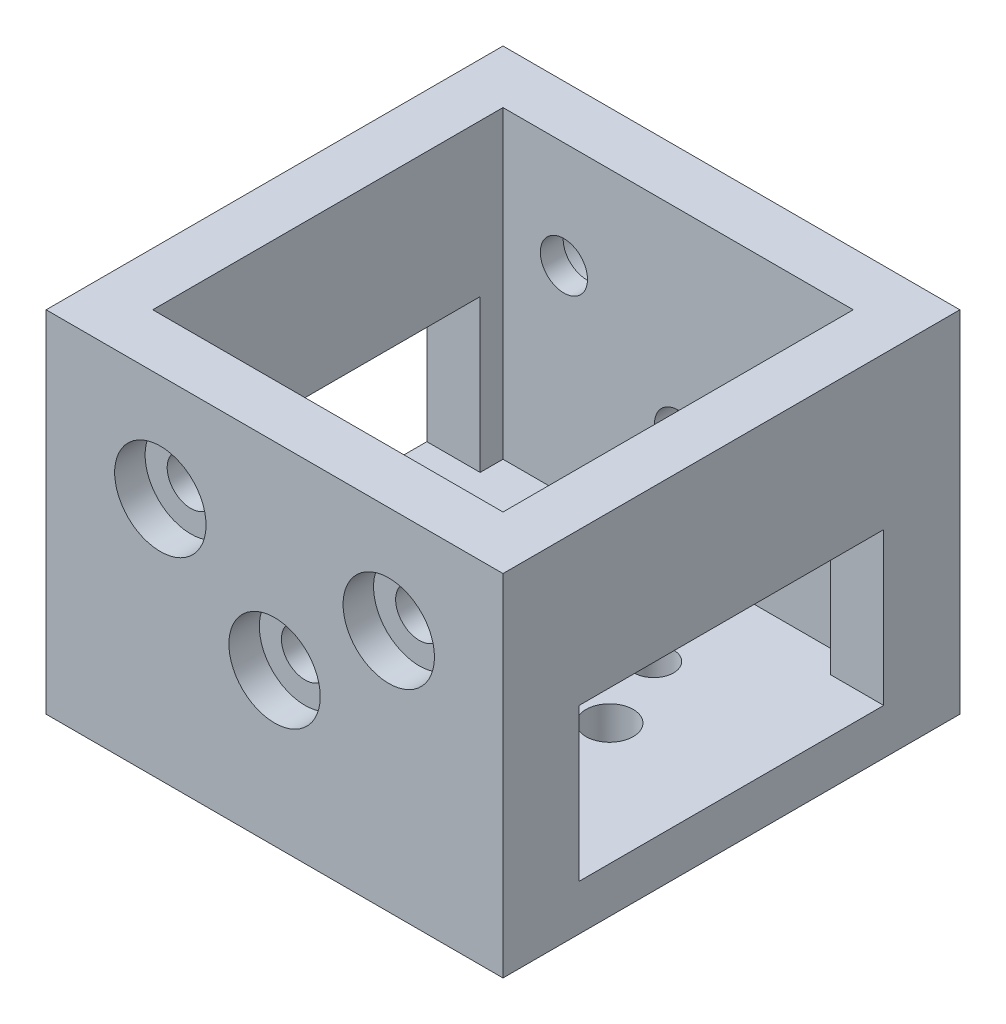
from build123d import *

# Parameters (mm, degrees)
SKETCH_1_W          = 23
SKETCH_1_H          = 30
EXTRUDE_2_DEPTH     = 3
SKETCH_1_4_W        = 23
SKETCH_1_4_H        = 3.5
EXTRUDE_3_DEPTH     = 18
EXTRUDE_3_2_DEPTH   = 18
SKETCH_1_5_W        = 30
SKETCH_1_5_H        = 30
SKETCH_1_5_W_2      = 23
SKETCH_1_5_H_2      = 23
EXTRUDE_4_DEPTH     = 23
SKETCH_3_R          = 1.55
CUT_EXTRUDE_2_DEPTH = 45.171936792
CUT_EXTRUDE_5_DEPTH = 41.669398815
SKETCH_9_R          = 1.3
SKETCH_9_R_2        = 3
SKETCH_9_R_3        = 1.55
CUT_EXTRUDE_6_DEPTH = 32.288975694
SKETCH_10_R         = 3
CUT_EXTRUDE_7_DEPTH = 2
CUT_EXTRUDE_START   = -2
SKETCH_11_R         = 3
CUT_EXTRUDE_8_DEPTH = 2


with BuildPart() as part:
    # 草图1 → 凸台-拉伸2 (new body)
    with BuildSketch(Plane(origin=(0, 0, 0), x_dir=(1, 0, 0), z_dir=(0, 1, 0))):
        Rectangle(SKETCH_1_W, SKETCH_1_H)
    extrude(amount=EXTRUDE_2_DEPTH)



with BuildPart() as body_2:
    # 草图1<4> → 凸台-拉伸3 (new body)
    with BuildSketch(Plane(origin=(0, 0, 0), x_dir=(1, 0, 0), z_dir=(0, 1, 0))):
        with Locations((0, 13.25)):
            Rectangle(SKETCH_1_4_W, SKETCH_1_4_H)
    extrude(amount=EXTRUDE_3_DEPTH)


with BuildPart() as body_3:
    # 草图1<4> → Extrude 3 2 (new body)
    with BuildSketch(Plane(origin=(0, 0, 0), x_dir=(1, 0, 0), z_dir=(0, 1, 0))):
        with Locations((0, -13.25)):
            Rectangle(SKETCH_1_4_W, SKETCH_1_4_H)
    extrude(amount=EXTRUDE_3_2_DEPTH)


with BuildPart() as part_1:
    add(part.part)

    add(body_2.part)  # 凸台-拉伸4 merges body 2

    add(body_3.part)  # 凸台-拉伸4 merges body 3
    # 草图1<5> → 凸台-拉伸4 (add)
    with BuildSketch(Plane(origin=(0, 0, 0), x_dir=(1, 0, 0), z_dir=(0, 1, 0))):
        Rectangle(SKETCH_1_5_W, SKETCH_1_5_H)
        Rectangle(SKETCH_1_5_W_2, SKETCH_1_5_H_2, mode=Mode.SUBTRACT)
    extrude(amount=EXTRUDE_4_DEPTH)

    # 草图3 → 切除-拉伸2 (cut, through all)
    with BuildSketch(Plane(origin=(0, 0, -19.6), x_dir=(-1, 0, 0), z_dir=(0, 0, -1))):
        with Locations((0, 10)):
            Circle(SKETCH_3_R)
        with Locations((-7.5, 16)):
            Circle(SKETCH_3_R)
        with Locations((7.5, 16)):
            Circle(SKETCH_3_R)
    extrude(amount=-CUT_EXTRUDE_2_DEPTH, mode=Mode.SUBTRACT)

    # 草图8 → 切除-拉伸5 (cut, through all)
    with BuildSketch(Plane.ZY.offset(15)):
        Polygon((10, 3), (10, 10), (10, 13), (-10, 13), (-10, 3), (0, 3), align=None)
    extrude(amount=-CUT_EXTRUDE_5_DEPTH, mode=Mode.SUBTRACT)

    # 草图9 → 切除-拉伸6 (cut, through all)
    with BuildSketch(Plane.XZ):
        with Locations((-4.949747468, -4.949747468)):
            Circle(SKETCH_9_R)
        with Locations((4.949747468, -4.949747468)):
            Circle(SKETCH_9_R)
        with Locations((4.949747468, 4.949747468)):
            Circle(SKETCH_9_R)
        with Locations((-4.949747468, 4.949747468)):
            Circle(SKETCH_9_R)
        Circle(SKETCH_9_R_2)
        with Locations((7, 0)):
            Circle(SKETCH_9_R_3)
        with Locations((0, 7)):
            Circle(SKETCH_9_R_3)
        with Locations((0, -7)):
            Circle(SKETCH_9_R_3)
        with Locations((-7, 0)):
            Circle(SKETCH_9_R_3)
    extrude(amount=-CUT_EXTRUDE_6_DEPTH, mode=Mode.SUBTRACT)

    # 草图10 → 切除-拉伸7 (cut)
    with BuildSketch(Plane(origin=(0, 0, -15), x_dir=(-1, 0, 0), z_dir=(0, 0, -1))):
        with Locations((7.5, 16)):
            Circle(SKETCH_10_R)
        with Locations((0, 10)):
            Circle(SKETCH_10_R)
        with Locations((-7.5, 16)):
            Circle(SKETCH_10_R)
    extrude(amount=-CUT_EXTRUDE_7_DEPTH, mode=Mode.SUBTRACT)

    # 草图11 → 切除-拉伸8 (cut)
    with BuildSketch(Plane.XY.offset(15).offset(CUT_EXTRUDE_START)):
        with Locations((-7.5, 16)):
            Circle(SKETCH_11_R)
        with Locations((0, 10)):
            Circle(SKETCH_11_R)
        with Locations((7.5, 16)):
            Circle(SKETCH_11_R)
    extrude(amount=CUT_EXTRUDE_8_DEPTH, mode=Mode.SUBTRACT)


solid = part_1.part
